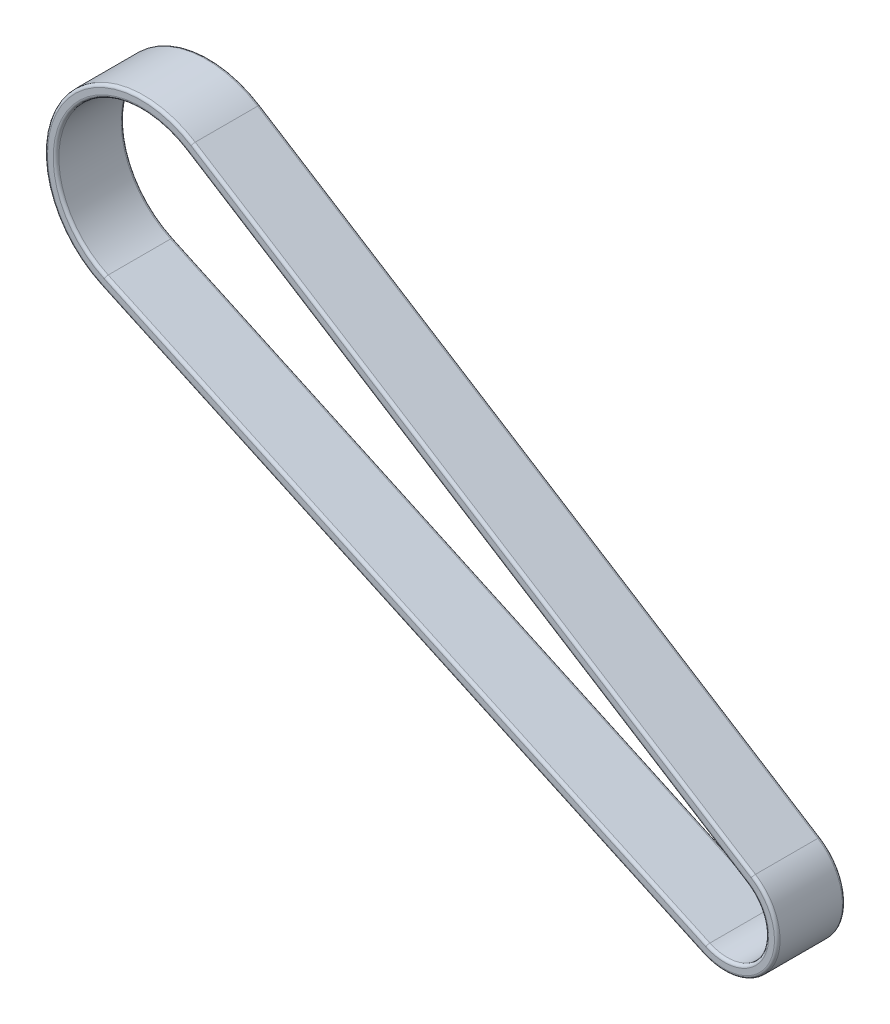
from build123d import *

# Parameters (mm, degrees)
SURFACE_EXTRUDE4_1_BACK  = 5
SURFACE_EXTRUDE4_1_DEPTH = 12
THICKEN3_T1              = 2
FILLET3_R                = 0.5


with BuildPart() as body_1:
    # Surface-Extrude4: a surface, the sketch's curves swept straight by 12 mm
    with BuildLine(Plane.XY.offset(-SURFACE_EXTRUDE4_1_BACK), mode=Mode.PRIVATE) as surface_extrude4_1_path:
        Line((-3.067605851, -6.646088585), (-109.286177334, 42.380749855))
        ThreePointArc((-109.286177334, 42.380749855), (-116.178200525, 63.164846887), (-94.987263263, 68.680538237))
        Line((-94.987263263, 68.680538237), (3.910153467, 6.188004445))
        ThreePointArc((3.910153467, 6.188004445), (6.430859787, -3.496389787), (-3.067605851, -6.646088585))
    surface_extrude4_1 = Shell.extrude(surface_extrude4_1_path.wire(), (0 * SURFACE_EXTRUDE4_1_DEPTH, 0 * SURFACE_EXTRUDE4_1_DEPTH, 1 * SURFACE_EXTRUDE4_1_DEPTH))
    add(Solid.thicken(surface_extrude4_1, THICKEN3_T1))

    # Fillet3
    fillet3_edges = [body_1.edges().sort_by_distance(p)[0] for p in [
        (6.430859787, -3.496389787, -5),
        (-56.176891592, 17.867330635, -5),
        (-116.178200525, 63.164846887, -5),
        (-45.538554898, 37.434271341, -5),
        (8.18795319, -4.451702705, 7),
        (-57.01504857, 16.051430615, 7),
        (-117.935293928, 64.120159806, 7),
        (-44.47019, 39.125009772, 7),
        (8.18795319, -4.451702705, -5),
        (-57.01504857, 16.051430615, -5),
        (-117.935293928, 64.120159806, -5),
        (-44.47019, 39.125009772, -5),
        (-45.538554898, 37.434271341, 7),
        (-116.178200525, 63.164846887, 7),
        (-56.176891592, 17.867330635, 7),
        (6.430859787, -3.496389787, 7),
    ]]
    fillet(fillet3_edges, radius=FILLET3_R)


solid = body_1.part
